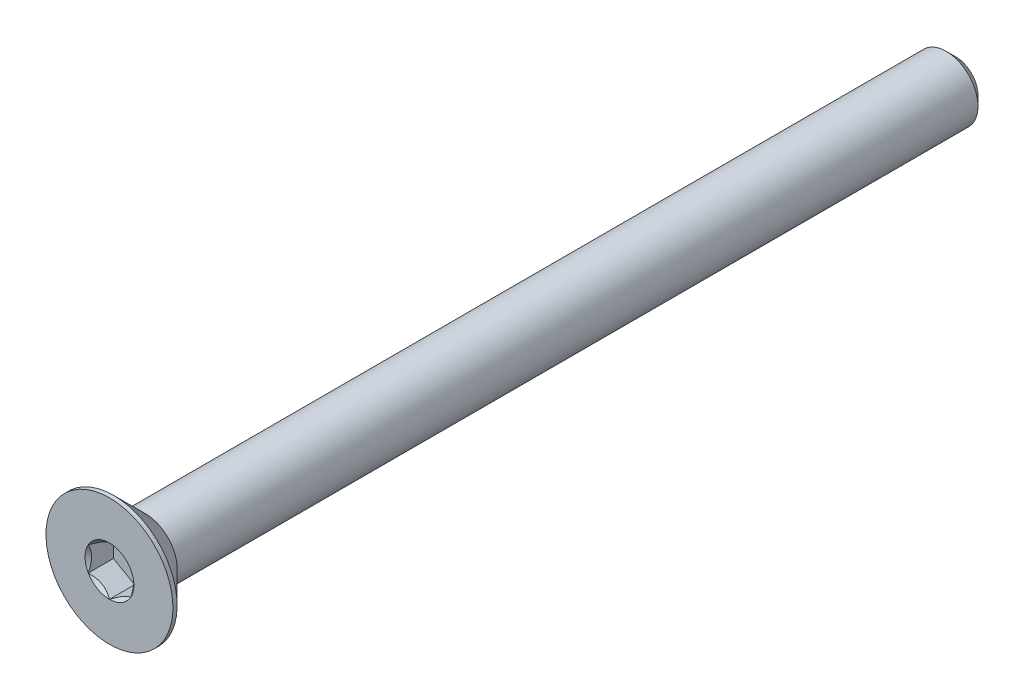
from build123d import *

# Parameters (mm, degrees)
SKETCH3_W          = 40
SKETCH3_H          = 1.5
CHAMFER1_SIZE      = 0.45
CUT_EXTRUDE1_DEPTH = 1.19


with BuildPart() as part:
    # Sketch3 → Revolve1 (revolve)
    with BuildSketch(Plane(origin=(0, 0, 0), x_dir=(0, 0, -1), z_dir=(1, 0, 0))):
        with Locations((0, 0.75)):
            Rectangle(SKETCH3_W, SKETCH3_H)
    revolve(axis=Axis((0, 0, -20), (0, 0, 1)))

    # Chamfer1
    chamfer1_edges = [part.edges().sort_by_distance(p)[0] for p in [
        (0, -1.5, -20),
    ]]
    chamfer(chamfer1_edges, length=CHAMFER1_SIZE)

    # Sketch6 → Revolve2 (revolve)
    with BuildSketch(Plane(origin=(0, 0, 0), x_dir=(0, 0, -1), z_dir=(1, 0, 0))):
        Polygon((-20, 3), (-19.8, 3), (-18.3, 1.5), (-18.3, 0), (-20, 0), align=None)
    revolve(axis=Axis((0, 0, -20), (0, 0, 1)))

    # Sketch8 → Cut-Extrude1 (cut)
    with BuildSketch(Plane.XY.offset(20)):
        Polygon((0, 1.154700538), (-1, 0.577350269), (-1, -0.577350269), (0, -1.154700538), (1, -0.577350269), (1, 0.577350269), align=None)
    extrude(amount=-CUT_EXTRUDE1_DEPTH, mode=Mode.SUBTRACT)

    # Cut-Extrude2 cone 1 section (through the dimple's axis) → Cut-Extrude2 (revolve, cut)
    with BuildSketch(Plane(origin=(0, 0, 20), x_dir=(0, -1, 0), z_dir=(1, 0, 0))):
        Polygon((0, 0), (1.154700538, 0), (0, 1.154700538), align=None)
    revolve(axis=Axis((0, 0, 20), (0, 0, -1)), mode=Mode.SUBTRACT)


solid = part.part
